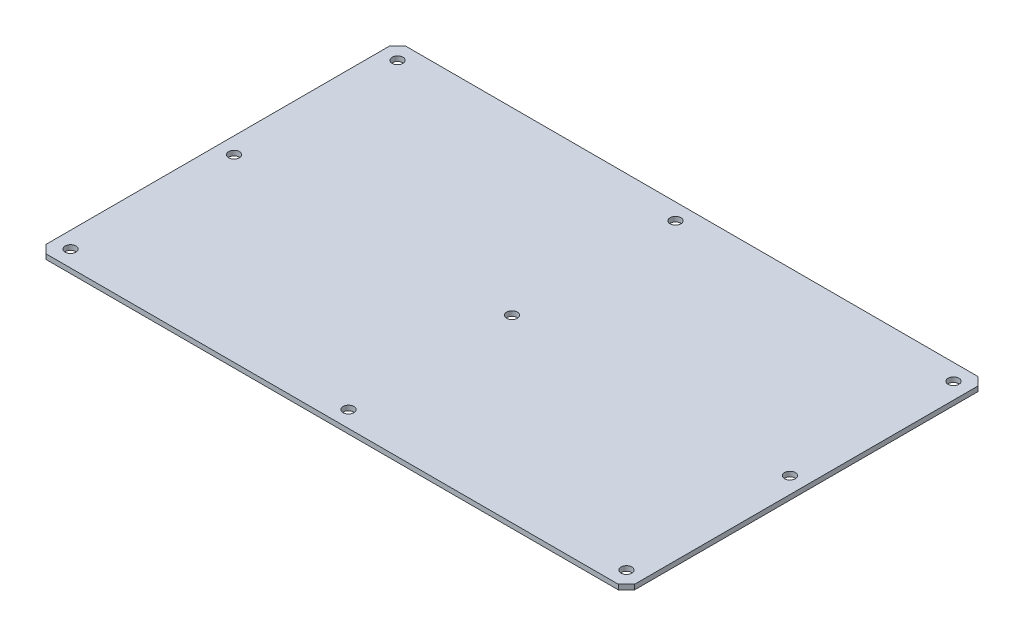
from build123d import *

# Parameters (mm, degrees)
ESQUISSE1_W          = 360
ESQUISSE1_H          = 220
BOSS_EXTRU_1_DEPTH   = 3
M6_CLEARANCE_HOLE1_D = 6.6
CHAMFER1_SIZE        = 5


with BuildPart() as part:
    # Esquisse1 → Boss.-Extru.1 (new body)
    with BuildSketch(Plane(origin=(0, 0, 0), x_dir=(1, 0, 0), z_dir=(0, 1, 0))):
        Rectangle(ESQUISSE1_W, ESQUISSE1_H)
    extrude(amount=BOSS_EXTRU_1_DEPTH)

    # M6 Clearance Hole1 (through all)
    with Locations(Plane(origin=(0, 0, 0), x_dir=(-1, 0, 0), z_dir=(0, -1, 0))):
        with Locations((-170, 100), (0, 100), (170, 100), (0, 0), (170, 0), (0, -100), (170, -100), (-170, 0), (-170, -100)):
            Hole(M6_CLEARANCE_HOLE1_D / 2)

    # Chamfer1
    chamfer1_edges = [part.edges().sort_by_distance(p)[0] for p in [
        (180, 1.5, 110),
        (-180, 1.5, 110),
        (-180, 1.5, -110),
        (180, 1.5, -110),
    ]]
    chamfer(chamfer1_edges, length=CHAMFER1_SIZE)


solid = part.part
